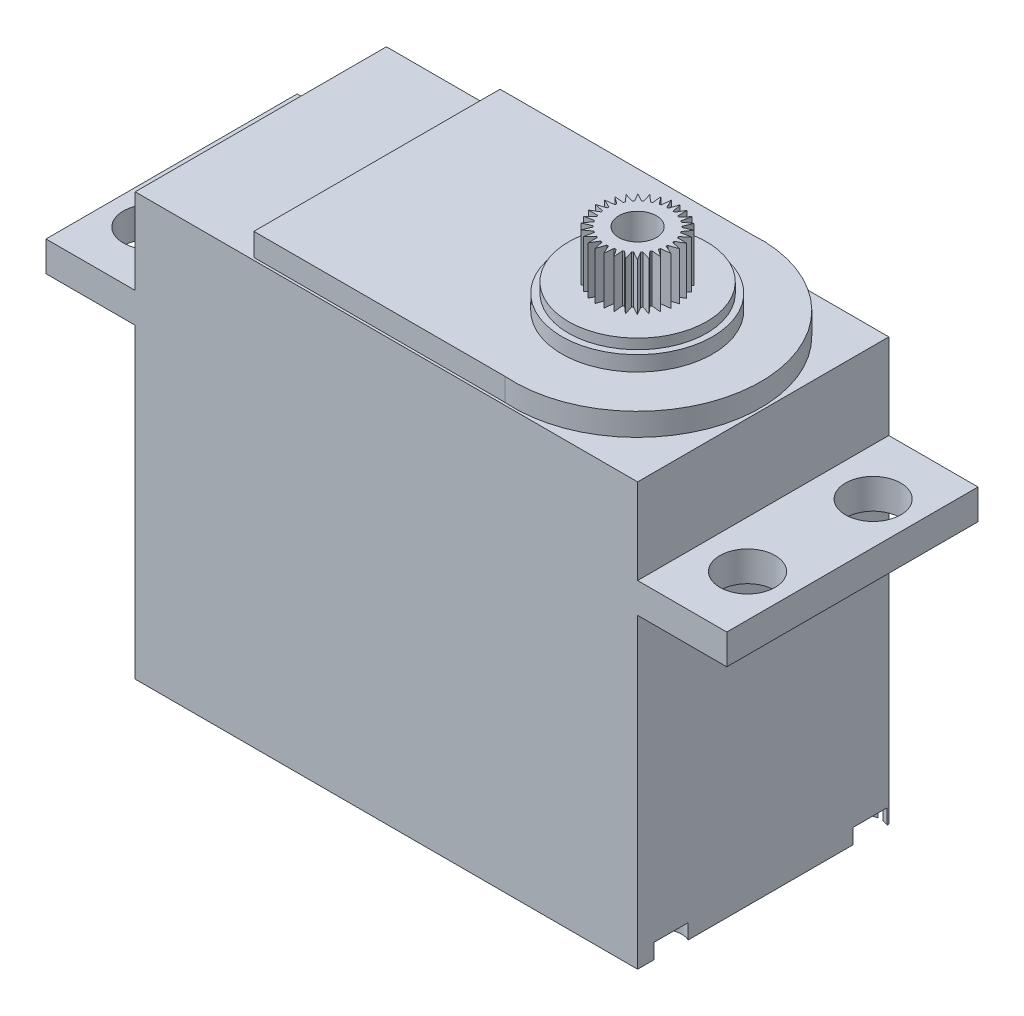
from build123d import *

# Parameters (mm, degrees)
SKETCH1_W           = 40
SKETCH1_H           = 33.6
BOSS_EXTRUDE1_DEPTH = 20
SKETCH2_W           = 7.1
SKETCH2_H           = 2.4
BOSS_EXTRUDE2_DEPTH = 20
SKETCH4_R           = 2.2
CUT_EXTRUDE1_DEPTH  = 3
BOSS_EXTRUDE4_DEPTH = 1.8
SKETCH6_R           = 1.5
CUT_EXTRUDE2_DEPTH  = 1.2
SKETCH7_R           = 6
BOSS_EXTRUDE5_DEPTH = 1.2
SKETCH8_R           = 5.5
BOSS_EXTRUDE6_DEPTH = 0.8
SKETCH10_R          = 2.5
BOSS_EXTRUDE8_DEPTH = 3.8
BOSS_EXTRUDE9_DEPTH = 4
CIRPATTERN2_COUNT   = 30
SKETCH12_R          = 1.5
CUT_EXTRUDE4_DEPTH  = 4


with BuildPart() as part:
    # Sketch1 → Boss-Extrude1 (new body)
    with BuildSketch(Plane.XY):
        with Locations((-4.683412042, -8.529571984)):
            Rectangle(SKETCH1_W, SKETCH1_H)
    extrude(amount=BOSS_EXTRUDE1_DEPTH)

    # Sketch2 → Boss-Extrude2 (add)
    with BuildSketch(Plane.XY.offset(20)):
        with Locations((18.866587958, 0.270428016)):
            Rectangle(SKETCH2_W, SKETCH2_H)
        with Locations((-28.233412042, 0.270428016)):
            Rectangle(SKETCH2_W, SKETCH2_H)
    extrude(amount=-BOSS_EXTRUDE2_DEPTH)

    # Sketch4 → Cut-Extrude1 (cut)
    with BuildSketch(Plane(origin=(0, 1.470428016, 0), x_dir=(1, 0, 0), z_dir=(0, 1, 0))):
        with Locations((19.066587958, -15)):
            Circle(SKETCH4_R)
        with Locations((19.066587958, -5)):
            Circle(SKETCH4_R)
        with Locations((-28.433412042, -15)):
            Circle(SKETCH4_R)
        with Locations((-28.433412042, -5)):
            Circle(SKETCH4_R)
    extrude(amount=-CUT_EXTRUDE1_DEPTH, mode=Mode.SUBTRACT)

    # Sketch5 → Boss-Extrude4 (add)
    with BuildSketch(Plane(origin=(0, 8.270428016, 0), x_dir=(1, 0, 0), z_dir=(0, 1, 0))):
        with BuildLine():
            Line((-15.433412042, -0.2), (-15.433412042, -19.8))
            Line((-15.433412042, -19.8), (4.566587958, -19.8))
            ThreePointArc((4.566587958, -19.8), (15.11483144, -10), (4.566587958, -0.2))
            Line((4.566587958, -0.2), (-15.433412042, -0.2))
        make_face()
    extrude(amount=BOSS_EXTRUDE4_DEPTH)

    # Sketch6 → Cut-Extrude2 (cut)
    with BuildSketch(Plane.XZ.offset(25.329571984)):
        with Locations((-22.660585011, 17.329722527)):
            Circle(SKETCH6_R)
        with Locations((-22.660585011, 1.487126069)):
            Circle(SKETCH6_R)
        with Locations((14.670467636, 17.329722527)):
            Circle(SKETCH6_R)
        with Locations((14.670467636, 1.487126069)):
            Circle(SKETCH6_R)
    extrude(amount=-CUT_EXTRUDE2_DEPTH, mode=Mode.SUBTRACT)

    # Sketch7 → Boss-Extrude5 (add)
    with BuildSketch(Plane(origin=(0, 10.070428016, 0), x_dir=(1, 0, 0), z_dir=(0, 1, 0))):
        with Locations((5.288292978, -10)):
            Circle(SKETCH7_R)
    extrude(amount=BOSS_EXTRUDE5_DEPTH)

    # Sketch8 → Boss-Extrude6 (add)
    with BuildSketch(Plane(origin=(0, 11.270428016, 0), x_dir=(1, 0, 0), z_dir=(0, 1, 0))):
        with Locations((5.316587958, -10)):
            Circle(SKETCH8_R)
    extrude(amount=BOSS_EXTRUDE6_DEPTH)

    # Sketch10 → Boss-Extrude8 (add)
    with BuildSketch(Plane(origin=(0, 12.070428016, 0), x_dir=(1, 0, 0), z_dir=(0, 1, 0))):
        with Locations((5.316587958, -10)):
            Circle(SKETCH10_R)
    extrude(amount=BOSS_EXTRUDE8_DEPTH)

    # Sketch11 → Boss-Extrude9 (add)
    with BuildSketch(Plane(origin=(0, 15.870428016, 0), x_dir=(1, 0, 0), z_dir=(0, 1, 0))):
        Polygon((5.503448723, -6.801928291), (5.271899273, -7.500399448), (5.664716985, -7.524357421), align=None)
    boss_extrude9 = extrude(amount=-BOSS_EXTRUDE9_DEPTH)

    # CirPattern2: Boss-Extrude9 ×30 about axis
    cirpattern2_axis = Axis((5.316587958, 0, 10), (0, 1, 0))
    for i in range(1, CIRPATTERN2_COUNT):
        add(boss_extrude9.rotate(cirpattern2_axis, i * 360 / CIRPATTERN2_COUNT))

    # Sketch12 → Cut-Extrude4 (cut)
    with BuildSketch(Plane(origin=(0, 15.870428016, 0), x_dir=(1, 0, 0), z_dir=(0, 1, 0))):
        with Locations((5.316587958, -10)):
            Circle(SKETCH12_R)
    extrude(amount=-CUT_EXTRUDE4_DEPTH, mode=Mode.SUBTRACT)


solid = part.part
